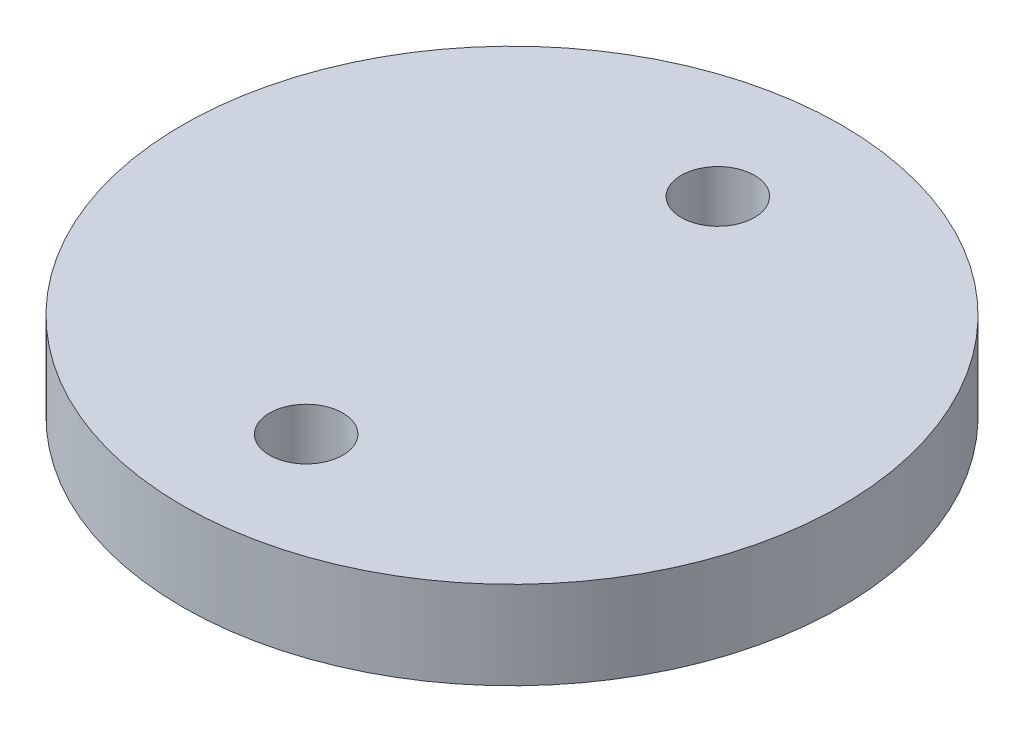
from build123d import *

# Parameters (mm, degrees)
SKETCH1_R           = 11.43
SKETCH1_R_2         = 1.27
BOSS_EXTRUDE1_DEPTH = 3.048


with BuildPart() as part:
    # Sketch1 → Boss-Extrude1 (new body)
    with BuildSketch(Plane(origin=(0, 0, 0), x_dir=(1, 0, 0), z_dir=(0, 1, 0))):
        Circle(SKETCH1_R)
        with Locations((0, 7.139305)):
            Circle(SKETCH1_R_2, mode=Mode.SUBTRACT)
        with Locations((0, -7.139305)):
            Circle(SKETCH1_R_2, mode=Mode.SUBTRACT)
    extrude(amount=BOSS_EXTRUDE1_DEPTH)


solid = part.part
